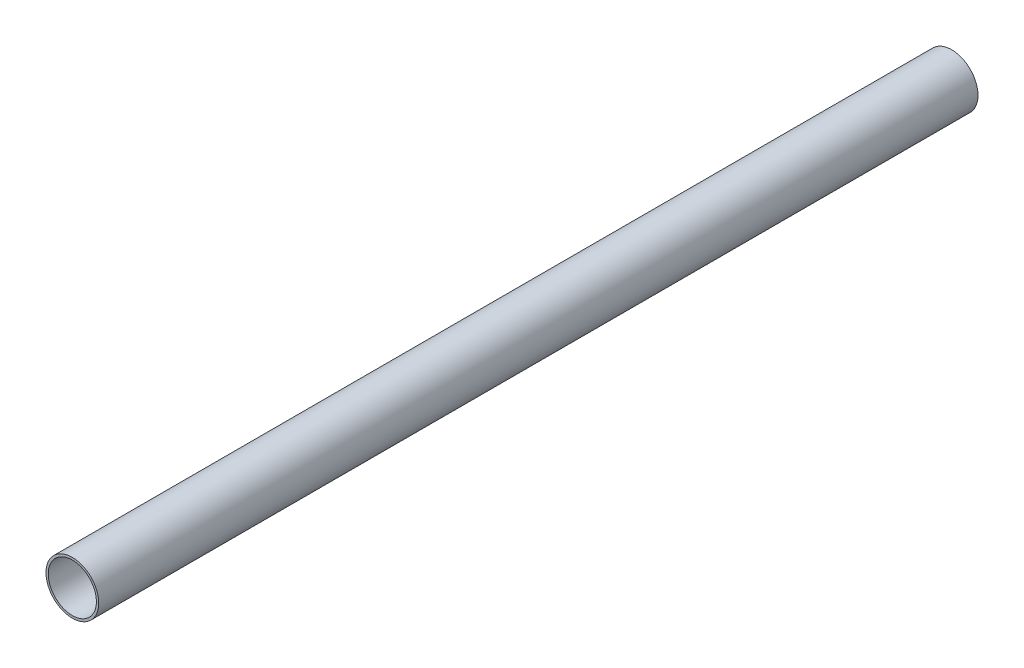
from build123d import *

# Parameters (mm, degrees)
ESQUISSE1_R        = 12
ESQUISSE1_R_2      = 10.95
BOSS_EXTRU_1_DEPTH = 400


with BuildPart() as part:
    # Esquisse1 → Boss.-Extru.1 (new body)
    with BuildSketch(Plane.XY):
        Circle(ESQUISSE1_R)
        Circle(ESQUISSE1_R_2, mode=Mode.SUBTRACT)
    extrude(amount=BOSS_EXTRU_1_DEPTH)


solid = part.part
